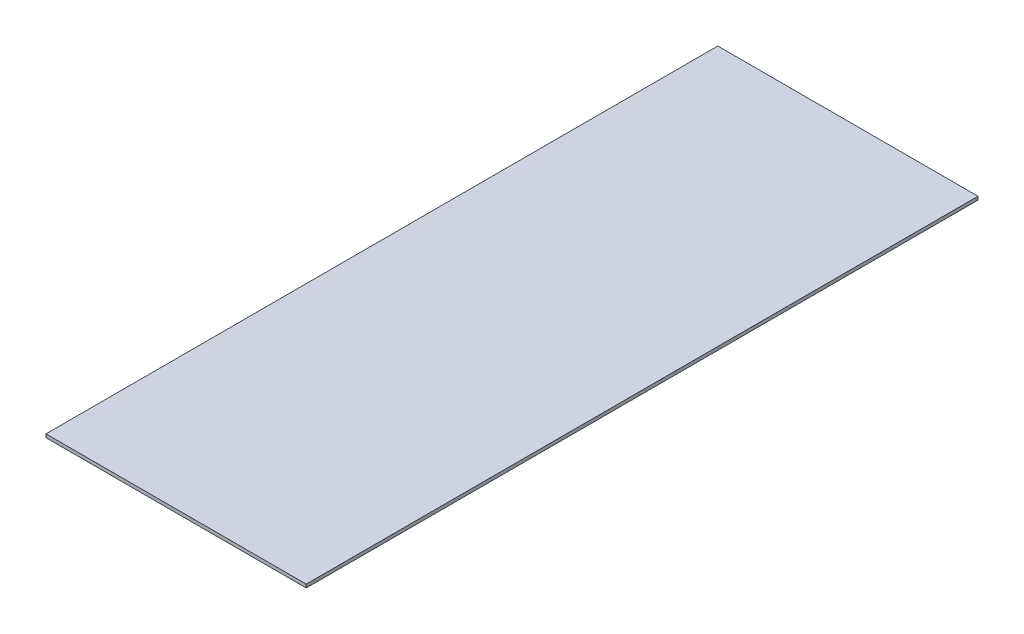
from build123d import *

# Parameters (mm, degrees)
CROQUIS1_W              = 230.94
CROQUIS1_H              = 596.2
SALIENTE_EXTRUIR1_DEPTH = 3


with BuildPart() as part:
    # Croquis1 → Saliente-Extruir1 (new body)
    with BuildSketch(Plane(origin=(0, 0, 0), x_dir=(1, 0, 0), z_dir=(0, 1, 0))):
        Rectangle(CROQUIS1_W, CROQUIS1_H)
    extrude(amount=SALIENTE_EXTRUIR1_DEPTH)


solid = part.part
